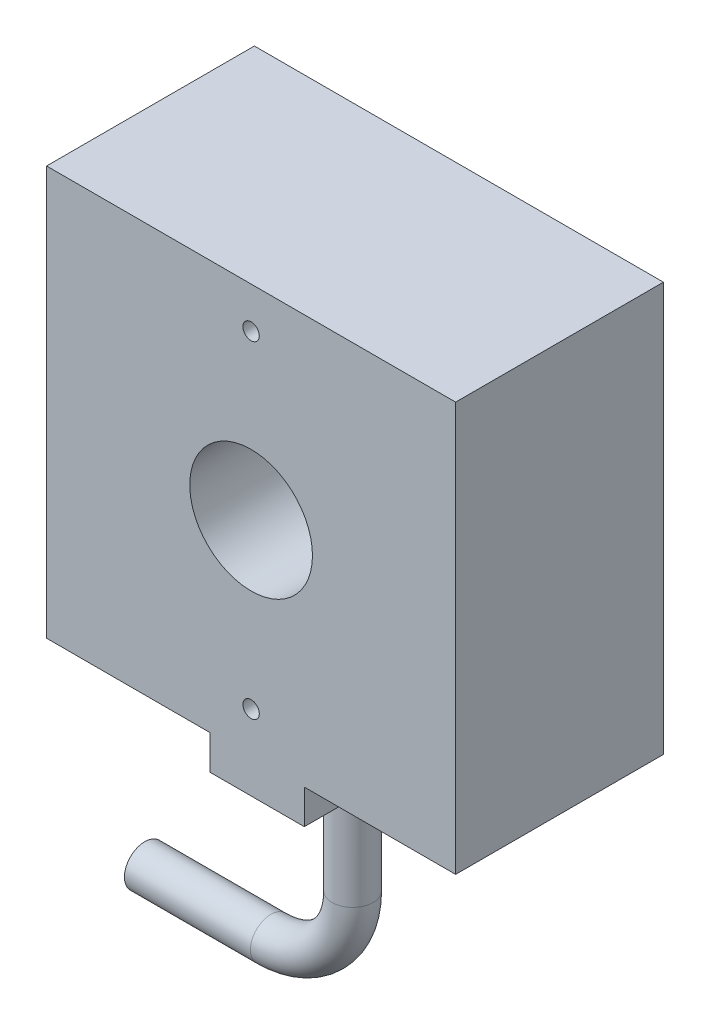
from build123d import *

# Parameters (mm, degrees)
SKETCH1_W           = 50
SKETCH1_H           = 50
BOSS_EXTRUDE1_DEPTH = 25.4
SKETCH2_R           = 7.5
SKETCH2_R_2         = 1
CUT_EXTRUDE1_DEPTH  = 26.4
SKETCH3_W           = 11.506935687
SKETCH3_H           = 4.197505038
BOSS_EXTRUDE2_DEPTH = 25.4
SKETCH4_R           = 2.5


with BuildPart() as part:
    # Sketch1 → Boss-Extrude1 (new body)
    with BuildSketch(Plane.XY):
        with Locations((25, 25)):
            Rectangle(SKETCH1_W, SKETCH1_H)
    extrude(amount=BOSS_EXTRUDE1_DEPTH)

    # Sketch2 → Cut-Extrude1 (cut, through all)
    with BuildSketch(Plane.XY.offset(25.4)):
        with Locations((25, 25)):
            Circle(SKETCH2_R)
        with Locations((25, 45)):
            Circle(SKETCH2_R_2)
        with Locations((25, 5)):
            Circle(SKETCH2_R_2)
    extrude(amount=-CUT_EXTRUDE1_DEPTH, mode=Mode.SUBTRACT)

    # Sketch3 → Boss-Extrude2 (add)
    with BuildSketch(Plane.XY.offset(25.4)):
        with Locations((25.752790186, -2.098752519)):
            Rectangle(SKETCH3_W, SKETCH3_H)
    extrude(amount=-BOSS_EXTRUDE2_DEPTH)

    # Sweep1: sweep along a path in Sketch5
    with BuildLine(Plane(origin=(0, 0, 13.825315415), x_dir=(-1, 0, 0), z_dir=(0, 0, -1))) as sweep1_path:
        Line((-25.836773001, -4.197505038), (-25.836773001, -19.597505038))
        ThreePointArc((-25.836773001, -19.597505038), (-22.907840813, -26.66857285), (-15.836773001, -29.597505038))
        Line((-15.836773001, -29.597505038), (-0.436773001, -29.597505038))
    # Sketch4 → Sweep1 (sweep)
    with BuildSketch(Plane.XZ.offset(4.197505038)):
        with Locations((25.836773001, 13.825315415)):
            Circle(SKETCH4_R)
    sweep(path=sweep1_path.line)


solid = part.part
